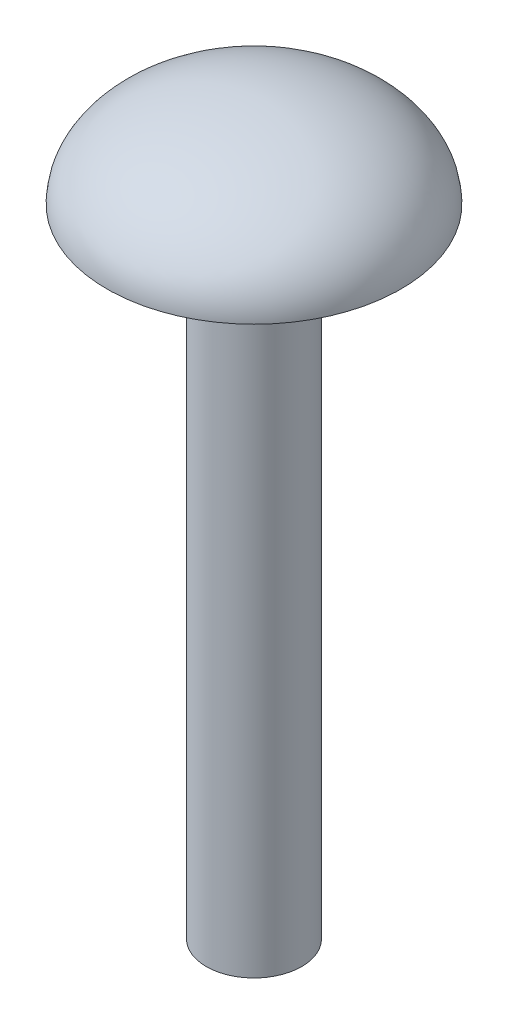
from build123d import *

# Parameters (mm, degrees)
SKETCH3_R           = 1.499728184
BOSS_EXTRUDE1_DEPTH = 20


with BuildPart() as part:
    # Sketch2 → Revolve1 (revolve)
    with BuildSketch(Plane.XY):
        with BuildLine():
            Line((-4.62, 0), (0, 0))
            Line((0, 0), (0, 2.81))
            add(Edge.make_bspline(
                [(0, 2.81), (-4.62, 2.81), (-4.62, 0)],
                knots=[4.71238898, 4.71238898, 4.71238898, 6.283185307, 6.283185307, 6.283185307], degree=2, weights=[1, 0.707106781, 1]))
        make_face()
    revolve(axis=Axis((0, 0, 0), (0, 1, 0)))

    # Sketch3 → Boss-Extrude1 (add)
    with BuildSketch(Plane(origin=(0, 0, 0), x_dir=(1, 0, 0), z_dir=(0, 1, 0))):
        Circle(SKETCH3_R)
    extrude(amount=-BOSS_EXTRUDE1_DEPTH)


solid = part.part
